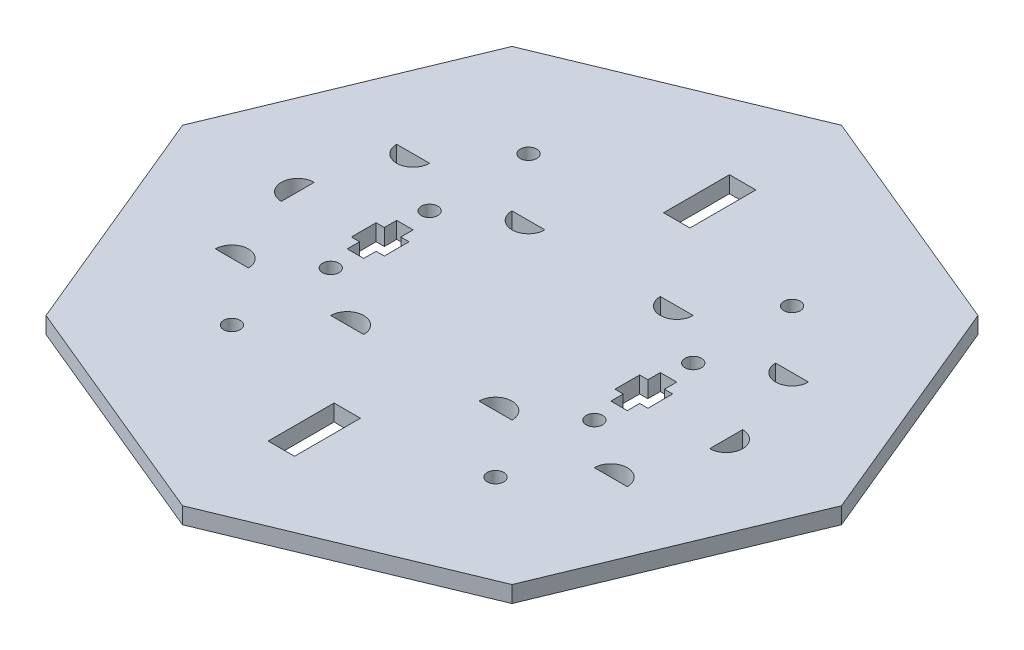
from build123d import *

# Parameters (mm, degrees)
SKETCH1_R      = 0.25
SKETCH1_W      = 0.8
SKETCH1_H      = 2
EXTRUDE1_DEPTH = 0.5
SKETCH2_R      = 0.25
EXTRUDE2_DEPTH = 1.5


with BuildPart() as part:
    # Sketch1 → Extrude1 (new body)
    with BuildSketch(Plane(origin=(0, 0, 0), x_dir=(1, 0, 0), z_dir=(0, 1, 0))):
        Polygon((-7.071067812, 7.071067812), (0, 10), (7.071067812, 7.071067812), (10, 0), (7.071067812, -7.071067812), (0, -10), (-7.071067812, -7.071067812), (-10, 0), align=None)
        with Locations((-4, 4.5)):
            Circle(SKETCH1_R, mode=Mode.SUBTRACT)
        with Locations((4, 4.5)):
            Circle(SKETCH1_R, mode=Mode.SUBTRACT)
        with Locations((4, -4.5)):
            Circle(SKETCH1_R, mode=Mode.SUBTRACT)
        with Locations((-4, -4.5)):
            Circle(SKETCH1_R, mode=Mode.SUBTRACT)
        with Locations((0, 6)):
            Rectangle(SKETCH1_W, SKETCH1_H, mode=Mode.SUBTRACT)
        with Locations((0, -6)):
            Rectangle(SKETCH1_W, SKETCH1_H, mode=Mode.SUBTRACT)
    extrude(amount=EXTRUDE1_DEPTH)

    # Sketch2 → Extrude2 (cut, through all)
    with BuildSketch(Plane(origin=(0, 0, 0), x_dir=(1, 0, 0), z_dir=(0, 1, 0))):
        with Locations((4, 1.5)):
            Circle(SKETCH2_R)
        with Locations((4, -1.5)):
            Circle(SKETCH2_R)
        with Locations((-4, 1.5)):
            Circle(SKETCH2_R)
        with Locations((-4, -1.5)):
            Circle(SKETCH2_R)
        Polygon((3.75, 0.75), (4.25, 0.75), (4.25, 0.375), (4.5, 0.375), (4.5, -0.375), (4.25, -0.375), (4.25, -0.75), (3.75, -0.75), (3.75, -0.375), (3.5, -0.375), (3.5, 0.375), (3.75, 0.375), align=None)
        Polygon((-3.5, 0.375), (-3.5, -0.375), (-3.75, -0.375), (-3.75, -0.75), (-4.25, -0.75), (-4.25, -0.375), (-4.5, -0.375), (-4.5, 0.375), (-4.25, 0.375), (-4.25, 0.75), (-3.75, 0.75), (-3.75, 0.375), align=None)
        with BuildLine():
            Line((-6.5, 0.5), (-6.5, -0.5))
            ThreePointArc((-6.5, -0.5), (-7, 0), (-6.5, 0.5))
        make_face()
        with BuildLine():
            Line((6.5, 0.5), (6.5, -0.5))
            ThreePointArc((6.5, -0.5), (7, 0), (6.5, 0.5))
        make_face()
        with BuildLine():
            Line((-6.25, 2.75), (-5.25, 2.75))
            ThreePointArc((-5.25, 2.75), (-5.75, 2.25), (-6.25, 2.75))
        make_face()
        with BuildLine():
            Line((-2.75, 2.75), (-1.75, 2.75))
            ThreePointArc((-1.75, 2.75), (-2.25, 2.25), (-2.75, 2.75))
        make_face()
        with BuildLine():
            Line((1.75, 2.75), (2.75, 2.75))
            ThreePointArc((2.75, 2.75), (2.25, 2.25), (1.75, 2.75))
        make_face()
        with BuildLine():
            Line((5.25, 2.75), (6.25, 2.75))
            ThreePointArc((6.25, 2.75), (5.75, 2.25), (5.25, 2.75))
        make_face()
        with BuildLine():
            Line((-6.25, -2.75), (-5.25, -2.75))
            ThreePointArc((-5.25, -2.75), (-5.75, -2.25), (-6.25, -2.75))
        make_face()
        with BuildLine():
            Line((-2.75, -2.75), (-1.75, -2.75))
            ThreePointArc((-1.75, -2.75), (-2.25, -2.25), (-2.75, -2.75))
        make_face()
        with BuildLine():
            Line((1.75, -2.75), (2.75, -2.75))
            ThreePointArc((2.75, -2.75), (2.25, -2.25), (1.75, -2.75))
        make_face()
        with BuildLine():
            Line((5.25, -2.75), (6.25, -2.75))
            ThreePointArc((6.25, -2.75), (5.75, -2.25), (5.25, -2.75))
        make_face()
    extrude(amount=EXTRUDE2_DEPTH, mode=Mode.SUBTRACT)


solid = part.part
